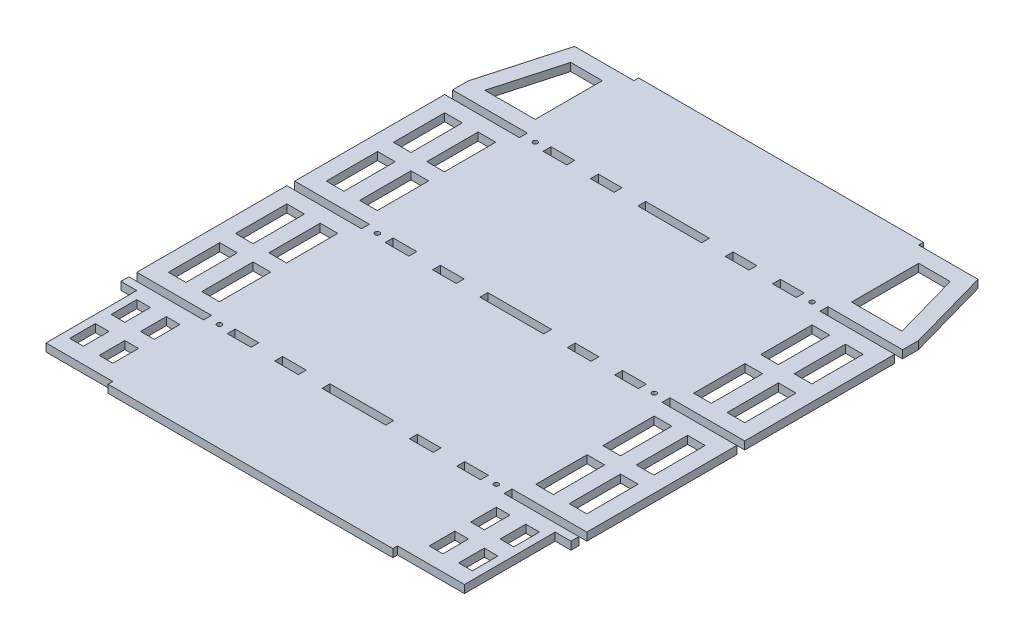
from build123d import *

# Parameters (mm, degrees)
SCHIZZO1_W                   = 285
SCHIZZO1_H                   = 330
ESTRUSIONE_ESTRUSIONE1_DEPTH = 5
SCHIZZO3_R                   = 1.5
SCHIZZO3_W                   = 40.36
SCHIZZO3_H                   = 5
SCHIZZO3_W_2                 = 15
SCHIZZO3_W_3                 = 47.32
TAGLIO_ESTRUSIONE1_DEPTH     = 6
SCHIZZO4_W                   = 180.34
SCHIZZO4_H                   = 5
ESTRUSIONE_ESTRUSIONE2_DEPTH = 3
SCHIZZO5_W                   = 180.36
SCHIZZO5_H                   = 5
ESTRUSIONE_ESTRUSIONE3_DEPTH = 3
SCHIZZO6_W                   = 8.66
SCHIZZO6_H                   = 16.25
SCHIZZO6_W_2                 = 11.16
SCHIZZO6_H_2                 = 32.5
SCHIZZO6_W_3                 = 10
SCHIZZO6_H_3                 = 57.5
TAGLIO_ESTRUSIONE2_DEPTH     = 6


with BuildPart() as part:
    # Schizzo1 → Estrusione-Estrusione1 (new body)
    with BuildSketch(Plane(origin=(0, 0, 0), x_dir=(1, 0, 0), z_dir=(0, 1, 0))):
        Rectangle(SCHIZZO1_W, SCHIZZO1_H)
    extrude(amount=ESTRUSIONE_ESTRUSIONE1_DEPTH)

    # Schizzo3 → Taglio-Estrusione1 (cut, through all)
    with BuildSketch(Plane(origin=(0, 0, 0), x_dir=(1, 0, 0), z_dir=(0, 1, 0))):
        with Locations((-87.68, 0)):
            Circle(SCHIZZO3_R)
        with Locations((87.68, 0)):
            Circle(SCHIZZO3_R)
        with Locations((-87.68, 100)):
            Circle(SCHIZZO3_R)
        with Locations((-87.68, -100)):
            Circle(SCHIZZO3_R)
        with Locations((87.68, -100)):
            Circle(SCHIZZO3_R)
        with Locations((87.68, 100)):
            Circle(SCHIZZO3_R)
        with Locations((-5.042705223, -204.043249359)):
            Circle(SCHIZZO3_R)
        with Locations((0, -100)):
            Rectangle(SCHIZZO3_W, SCHIZZO3_H)
        with Locations((-42.68, 0)):
            Rectangle(SCHIZZO3_W_2, SCHIZZO3_H)
        with Locations((-72.68, 0)):
            Rectangle(SCHIZZO3_W_2, SCHIZZO3_H)
        with Locations((72.68, 0)):
            Rectangle(SCHIZZO3_W_2, SCHIZZO3_H)
        with Locations((42.68, 0)):
            Rectangle(SCHIZZO3_W_2, SCHIZZO3_H)
        with Locations((-72.68, 100)):
            Rectangle(SCHIZZO3_W_2, SCHIZZO3_H)
        with Locations((-42.68, 100)):
            Rectangle(SCHIZZO3_W_2, SCHIZZO3_H)
        with Locations((-72.68, -100)):
            Rectangle(SCHIZZO3_W_2, SCHIZZO3_H)
        with Locations((-42.68, -100)):
            Rectangle(SCHIZZO3_W_2, SCHIZZO3_H)
        with Locations((42.68, 100)):
            Rectangle(SCHIZZO3_W_2, SCHIZZO3_H)
        with Locations((72.68, 100)):
            Rectangle(SCHIZZO3_W_2, SCHIZZO3_H)
        with Locations((42.68, -100)):
            Rectangle(SCHIZZO3_W_2, SCHIZZO3_H)
        with Locations((72.68, -100)):
            Rectangle(SCHIZZO3_W_2, SCHIZZO3_H)
        with Locations((-118.84, 100)):
            Rectangle(SCHIZZO3_W_3, SCHIZZO3_H)
        Rectangle(SCHIZZO3_W, SCHIZZO3_H)
        with Locations((0, 100)):
            Rectangle(SCHIZZO3_W, SCHIZZO3_H)
        with Locations((-118.84, 0)):
            Rectangle(SCHIZZO3_W_3, SCHIZZO3_H)
        with Locations((-118.84, -100)):
            Rectangle(SCHIZZO3_W_3, SCHIZZO3_H)
        with Locations((118.84, -100)):
            Rectangle(SCHIZZO3_W_3, SCHIZZO3_H)
        with Locations((118.84, 100)):
            Rectangle(SCHIZZO3_W_3, SCHIZZO3_H)
        with Locations((118.84, 0)):
            Rectangle(SCHIZZO3_W_3, SCHIZZO3_H)
    extrude(amount=TAGLIO_ESTRUSIONE1_DEPTH, mode=Mode.SUBTRACT)

    # Schizzo4 → Estrusione-Estrusione2 (add)
    with BuildSketch(Plane.XY.offset(165)):
        with Locations((0, 2.5)):
            Rectangle(SCHIZZO4_W, SCHIZZO4_H)
    extrude(amount=ESTRUSIONE_ESTRUSIONE2_DEPTH)

    # Schizzo5 → Estrusione-Estrusione3 (add)
    with BuildSketch(Plane(origin=(0, 0, -165), x_dir=(-1, 0, 0), z_dir=(0, 0, -1))):
        with Locations((0, 2.5)):
            Rectangle(SCHIZZO5_W, SCHIZZO5_H)
    extrude(amount=ESTRUSIONE_ESTRUSIONE3_DEPTH)

    # Schizzo6 → Taglio-Estrusione2 (cut, through all)
    with BuildSketch(Plane(origin=(0, 0, 0), x_dir=(1, 0, 0), z_dir=(0, 1, 0))):
        Polygon((-142.5, 165), (-127.75888719, 165), (-142.5, 112.5), align=None)
        Polygon((-132.113281799, 112.5), (-100.18, 112.5), (-100.18, 155), (-120.18, 155), align=None)
        with Locations((104.51, -146.875)):
            Rectangle(SCHIZZO6_W, SCHIZZO6_H)
        Polygon((132.113281799, 112.5), (100.18, 112.5), (100.18, 155), (120.18, 155), align=None)
        Polygon((142.5, 165), (127.75888719, 165), (142.5, 112.5), align=None)
        with Locations((-123.17, -120.625)):
            Rectangle(SCHIZZO6_W, SCHIZZO6_H)
        with Locations((-104.51, -120.625)):
            Rectangle(SCHIZZO6_W, SCHIZZO6_H)
        with Locations((-123.17, -146.875)):
            Rectangle(SCHIZZO6_W, SCHIZZO6_H)
        with Locations((-104.51, -146.875)):
            Rectangle(SCHIZZO6_W, SCHIZZO6_H)
        with Locations((123.17, -146.875)):
            Rectangle(SCHIZZO6_W, SCHIZZO6_H)
        with Locations((104.51, -120.625)):
            Rectangle(SCHIZZO6_W, SCHIZZO6_H)
        with Locations((123.17, -120.625)):
            Rectangle(SCHIZZO6_W, SCHIZZO6_H)
        with Locations((-126.92, -28.75)):
            Rectangle(SCHIZZO6_W_2, SCHIZZO6_H_2)
        with Locations((-105.76, -28.75)):
            Rectangle(SCHIZZO6_W_2, SCHIZZO6_H_2)
        with Locations((-126.92, -71.25)):
            Rectangle(SCHIZZO6_W_2, SCHIZZO6_H_2)
        with Locations((-105.76, -71.25)):
            Rectangle(SCHIZZO6_W_2, SCHIZZO6_H_2)
        with Locations((105.76, -71.25)):
            Rectangle(SCHIZZO6_W_2, SCHIZZO6_H_2)
        with Locations((126.92, -71.25)):
            Rectangle(SCHIZZO6_W_2, SCHIZZO6_H_2)
        with Locations((105.76, -28.75)):
            Rectangle(SCHIZZO6_W_2, SCHIZZO6_H_2)
        with Locations((126.92, -28.75)):
            Rectangle(SCHIZZO6_W_2, SCHIZZO6_H_2)
        with Locations((105.76, 71.25)):
            Rectangle(SCHIZZO6_W_2, SCHIZZO6_H_2)
        with Locations((126.92, 71.25)):
            Rectangle(SCHIZZO6_W_2, SCHIZZO6_H_2)
        with Locations((126.92, 28.75)):
            Rectangle(SCHIZZO6_W_2, SCHIZZO6_H_2)
        with Locations((105.76, 28.75)):
            Rectangle(SCHIZZO6_W_2, SCHIZZO6_H_2)
        with Locations((-126.92, 71.25)):
            Rectangle(SCHIZZO6_W_2, SCHIZZO6_H_2)
        with Locations((-105.76, 71.25)):
            Rectangle(SCHIZZO6_W_2, SCHIZZO6_H_2)
        with Locations((-105.76, 28.75)):
            Rectangle(SCHIZZO6_W_2, SCHIZZO6_H_2)
        with Locations((-126.92, 28.75)):
            Rectangle(SCHIZZO6_W_2, SCHIZZO6_H_2)
        with Locations((137.5, -136.25)):
            Rectangle(SCHIZZO6_W_3, SCHIZZO6_H_3)
        with Locations((-137.5, -136.25)):
            Rectangle(SCHIZZO6_W_3, SCHIZZO6_H_3)
    extrude(amount=TAGLIO_ESTRUSIONE2_DEPTH, mode=Mode.SUBTRACT)


solid = part.part
